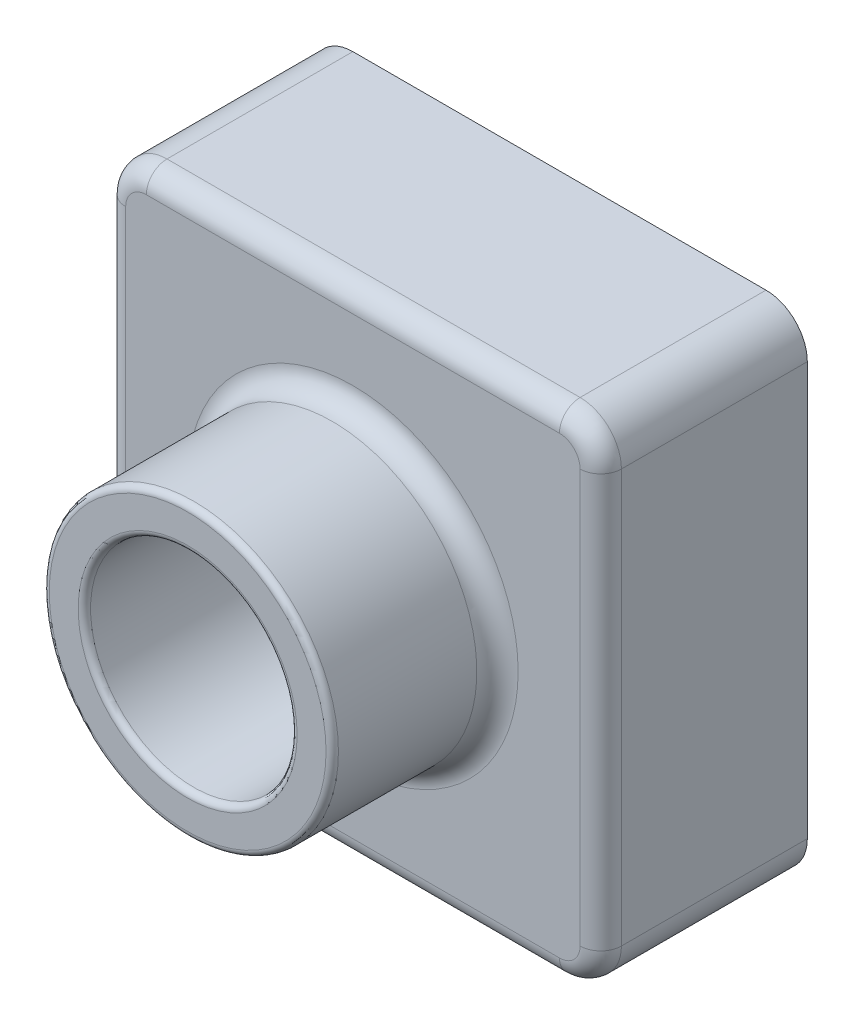
from build123d import *

# Parameters (mm, degrees)
SKETCH2_W           = 120
SKETCH2_H           = 120
BOSS_EXTRUDE1_DEPTH = 50
SKETCH4_R           = 35
BOSS_EXTRUDE2_DEPTH = 40
SKETCH6_R           = 25
CUT_EXTRUDE1_DEPTH  = 91
FILLET1_R           = 10
FILLET2_R           = 1.5
FILLET3_R           = 5
SHELL1_T            = -2


with BuildPart() as part:
    # Sketch2 → Boss-Extrude1 (new body)
    with BuildSketch(Plane.XY):
        with Locations((60, 60)):
            Rectangle(SKETCH2_W, SKETCH2_H)
    extrude(amount=BOSS_EXTRUDE1_DEPTH)

    # Sketch4 → Boss-Extrude2 (add)
    with BuildSketch(Plane.XY.offset(50)):
        with Locations((60, 60)):
            Circle(SKETCH4_R)
    extrude(amount=BOSS_EXTRUDE2_DEPTH)

    # Sketch6 → Cut-Extrude1 (cut, through all)
    with BuildSketch(Plane.XY.offset(90)):
        with Locations((60, 60)):
            Circle(SKETCH6_R)
    extrude(amount=-CUT_EXTRUDE1_DEPTH, mode=Mode.SUBTRACT)

    # Fillet1
    fillet1_edges = [part.edges().sort_by_distance(p)[0] for p in [
        (0, 120, 25),
        (120, 120, 25),
        (120, 0, 25),
        (0, 0, 25),
    ]]
    fillet(fillet1_edges, radius=FILLET1_R)

    # Fillet2
    fillet2_edges = [part.edges().sort_by_distance(p)[0] for p in [
        (25, 60, 90),
        (35, 60, 90),
    ]]
    fillet(fillet2_edges, radius=FILLET2_R)

    # Fillet3
    fillet3_edges = [part.edges().sort_by_distance(p)[0] for p in [
        (25, 60, 50),
        (60, 0, 50),
        (0, 60, 50),
        (120, 60, 50),
        (60, 120, 50),
        (2.928932188, 117.071067812, 50),
        (117.071067812, 117.071067812, 50),
        (117.071067812, 2.928932188, 50),
        (2.928932188, 2.928932188, 50),
    ]]
    fillet(fillet3_edges, radius=FILLET3_R)

    # Shell1
    shell1_openings = [part.faces().sort_by_distance(p)[0] for p in [
        (85, 60, 0),
    ]]
    offset(amount=SHELL1_T, openings=shell1_openings, kind=Kind.INTERSECTION)


solid = part.part
